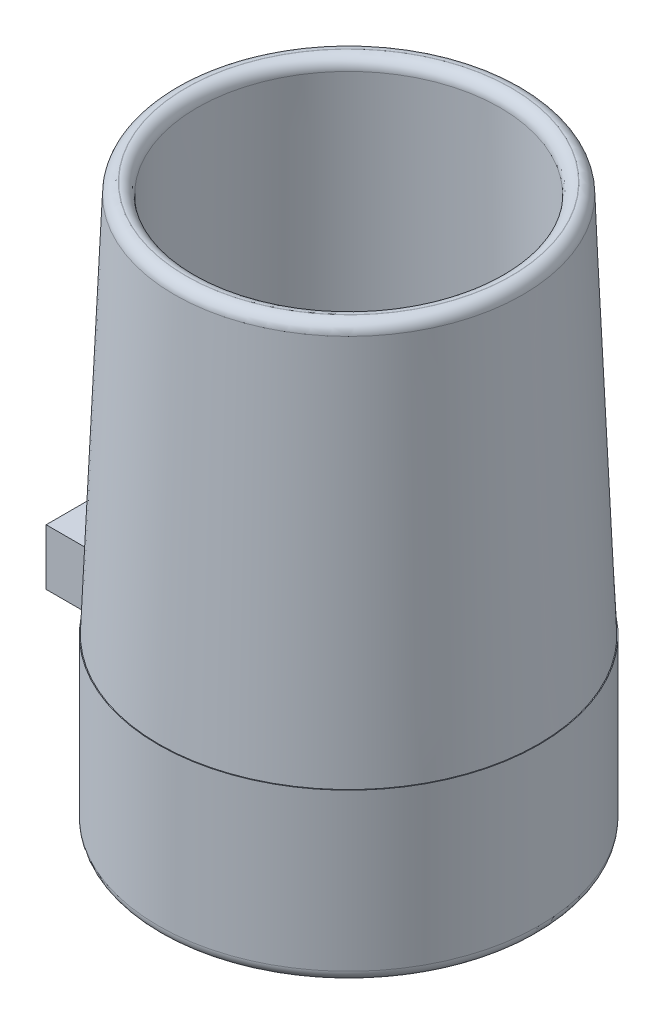
from build123d import *

# Parameters (mm, degrees)
SKETCH_1_R          = 17
SKETCH_1_R_2        = 14
EXTRUDE_1_DEPTH     = 15
SKETCH_2_R          = 15.1
SKETCH_2_R_2        = 14
CUT_EXTRUDE_1_DEPTH = 1.7
EXTRUDE_2_DEPTH     = 5
FILLET_1_R          = 1
FILLET_2_R          = 1


with BuildPart() as part:
    # 草图1 → 凸台-拉伸1 (new body)
    with BuildSketch(Plane(origin=(0, 0, 0), x_dir=(1, 0, 0), z_dir=(0, 1, 0))):
        Circle(SKETCH_1_R)
        Circle(SKETCH_1_R_2, mode=Mode.SUBTRACT)
    extrude(amount=EXTRUDE_1_DEPTH)

    # 草图2 → 切除-拉伸1 (cut)
    with BuildSketch(Plane(origin=(0, 0, 0), x_dir=(1, 0, 0), z_dir=(0, 1, 0))):
        Circle(SKETCH_2_R)
        Circle(SKETCH_2_R_2, mode=Mode.SUBTRACT)
    extrude(amount=CUT_EXTRUDE_1_DEPTH, mode=Mode.SUBTRACT)

    # 草图3 → 凸台-拉伸2 (add)
    with BuildSketch(Plane(origin=(0, 15, 0), x_dir=(1, 0, 0), z_dir=(0, 1, 0))):
        with BuildLine():
            Line((-22, 5), (-22, -5))
            Line((-22, -5), (-16.248076809, -5))
            ThreePointArc((-16.248076809, -5), (-17, 0), (-16.248076809, 5))
            Line((-16.248076809, 5), (-22, 5))
        make_face()
    extrude(amount=-EXTRUDE_2_DEPTH)

    # 草图11 → 旋转1 (revolve)
    with BuildSketch(Plane.XY):
        Polygon((13.5, 50), (14, 15), (16.933723731, 15), (15.5, 50), align=None)
    revolve(axis=Axis((0, 50, 0), (0, -1, 0)))

    # 圆角1
    fillet_1_edges = [part.edges().sort_by_distance(p)[0] for p in [
        (-17, 0, 0),
        (-15.5, 50, 0),
        (-13.5, 50, 0),
    ]]
    fillet(fillet_1_edges, radius=FILLET_1_R)

    # 圆角2
    fillet_2_edges = [part.edges().sort_by_distance(p)[0] for p in [
        (-16.248076809, 12.5, -5),
        (-16.248076809, 12.5, 5),
    ]]
    fillet(fillet_2_edges, radius=FILLET_2_R)


solid = part.part
